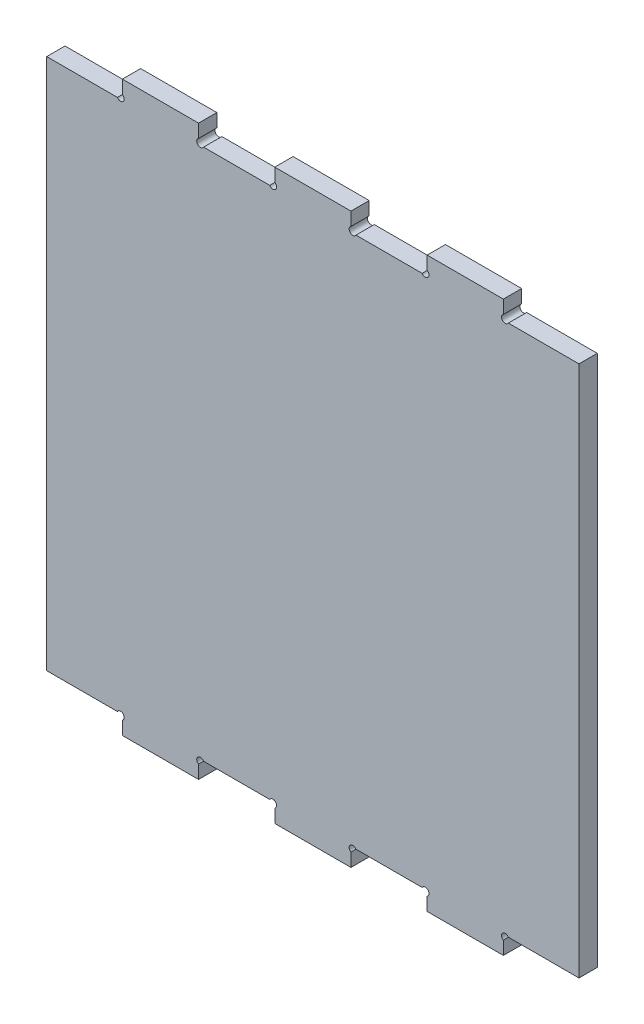
from build123d import *

# Parameters (mm, degrees)
BOSS_EXTRUDE1_DEPTH = 12


with BuildPart() as part:
    # Sketch1 → Boss-Extrude1 (new body)
    with BuildSketch(Plane.XY):
        with BuildLine():
            Line((-147.556413952, 174.626444756), (-101.192621764, 174.626444756))
            ThreePointArc((-101.192621764, 174.626444756), (-97.418155085, 174.138042833), (-97.917719368, 177.911048356))
            Line((-97.917719368, 177.911048356), (-97.917719368, 186.626444756))
            Line((-97.917719368, 186.626444756), (-47.917719368, 186.626444756))
            Line((-47.917719368, 186.626444756), (-47.917719368, 177.911048356))
            ThreePointArc((-47.917719368, 177.911048356), (-48.417283652, 174.138042833), (-44.642816972, 174.626444756))
            Line((-44.642816972, 174.626444756), (-1.192621764, 174.626444756))
            ThreePointArc((-1.192621764, 174.626444756), (2.581844915, 174.138042833), (2.082280632, 177.911048356))
            Line((2.082280632, 177.911048356), (2.082280632, 186.626444756))
            Line((2.082280632, 186.626444756), (52.082280632, 186.626444756))
            Line((52.082280632, 186.626444756), (52.082280632, 177.911048356))
            ThreePointArc((52.082280632, 177.911048356), (51.582716348, 174.138042833), (55.357183028, 174.626444756))
            Line((55.357183028, 174.626444756), (98.807378236, 174.626444756))
            ThreePointArc((98.807378236, 174.626444756), (102.581844915, 174.138042833), (102.082280632, 177.911048356))
            Line((102.082280632, 177.911048356), (102.082280632, 186.626444756))
            Line((102.082280632, 186.626444756), (152.082280632, 186.626444756))
            Line((152.082280632, 186.626444756), (152.082280632, 177.911048356))
            ThreePointArc((152.082280632, 177.911048356), (151.582716348, 174.138042833), (155.357183028, 174.626444756))
            Line((155.357183028, 174.626444756), (201.720975216, 174.626444756))
            Line((201.720975216, 174.626444756), (201.720975216, -174.373555244))
            Line((201.720975216, -174.373555244), (155.357183028, -174.373555244))
            ThreePointArc((155.357183028, -174.373555244), (151.582716348, -173.885153322), (152.082280632, -177.658158845))
            Line((152.082280632, -177.658158845), (152.082280632, -186.373555244))
            Line((152.082280632, -186.373555244), (102.082280632, -186.373555244))
            Line((102.082280632, -186.373555244), (102.082280632, -177.658158845))
            ThreePointArc((102.082280632, -177.658158845), (102.581844915, -173.885153322), (98.807378236, -174.373555244))
            Line((98.807378236, -174.373555244), (55.357183028, -174.373555244))
            ThreePointArc((55.357183028, -174.373555244), (51.582716348, -173.885153322), (52.082280632, -177.658158845))
            Line((52.082280632, -177.658158845), (52.082280632, -186.373555244))
            Line((52.082280632, -186.373555244), (2.082280632, -186.373555244))
            Line((2.082280632, -186.373555244), (2.082280632, -177.658158845))
            ThreePointArc((2.082280632, -177.658158845), (2.581844915, -173.885153322), (-1.192621764, -174.373555244))
            Line((-1.192621764, -174.373555244), (-44.642816972, -174.373555244))
            ThreePointArc((-44.642816972, -174.373555244), (-48.417283652, -173.885153322), (-47.917719368, -177.658158845))
            Line((-47.917719368, -177.658158845), (-47.917719368, -186.373555244))
            Line((-47.917719368, -186.373555244), (-97.917719368, -186.373555244))
            Line((-97.917719368, -186.373555244), (-97.917719368, -177.658158845))
            ThreePointArc((-97.917719368, -177.658158845), (-97.418155085, -173.885153322), (-101.192621764, -174.373555244))
            Line((-101.192621764, -174.373555244), (-147.556413952, -174.373555244))
            Line((-147.556413952, -174.373555244), (-147.556413952, 174.626444756))
        make_face()
    extrude(amount=BOSS_EXTRUDE1_DEPTH)


solid = part.part
